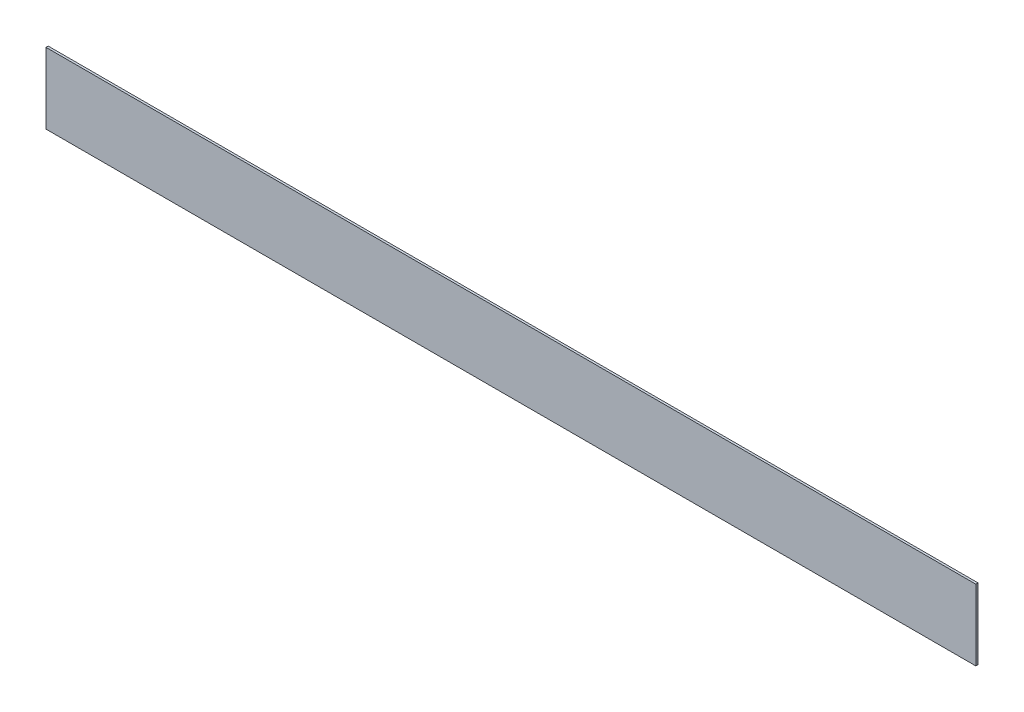
from build123d import *

# Parameters (mm, degrees)
SKETCH_1_W      = 42
SKETCH_1_H      = 3.2
EXTRUDE_1_DEPTH = 0.1


with BuildPart() as part:
    # 草图1 → 凸台-拉伸1 (new body)
    with BuildSketch(Plane.XY):
        Rectangle(SKETCH_1_W, SKETCH_1_H)
    extrude(amount=EXTRUDE_1_DEPTH)


solid = part.part
